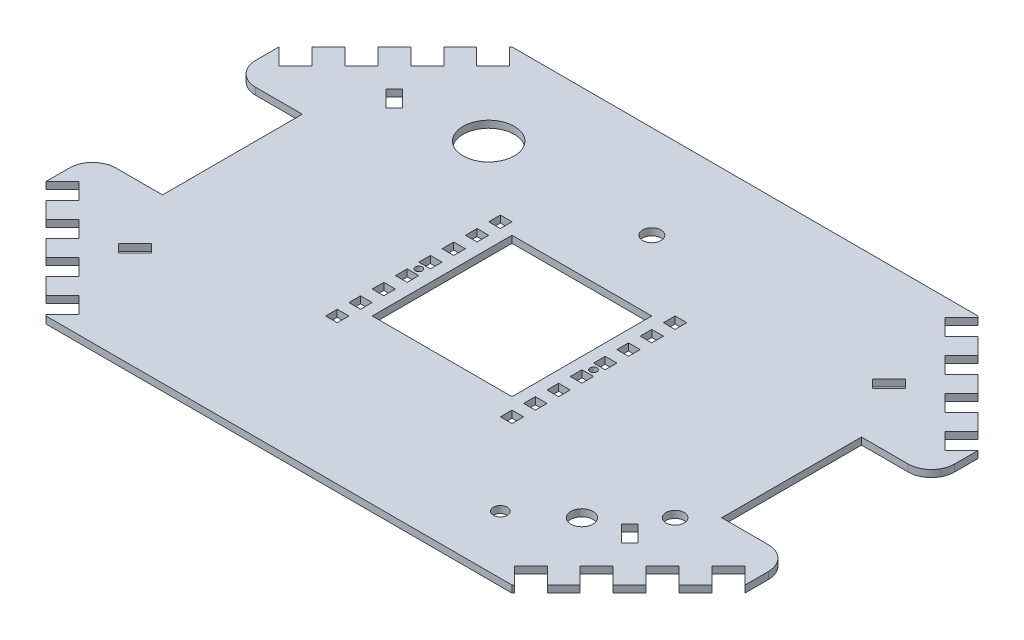
from build123d import *

# Parameters (mm, degrees)
ESQUISSE1_W                     = 300
ESQUISSE1_H                     = 200
BOSS_EXTRU_1_DEPTH              = 3
ENL_V_MAT_EXTRU_1_DEPTH         = 10
ESQUISSE3_W                     = 5
ESQUISSE3_H                     = 5
ENL_V_MAT_EXTRU_2_DEPTH         = 10
R_P_TITION_LIN_AIRE1_COUNT      = 2
R_P_TITION_LIN_AIRE1_PITCH      = 75
R_P_TITION_LIN_AIRE1_COUNT_DIR2 = 8
R_P_TITION_LIN_AIRE1_PITCH_DIR2 = 10
ENL_V_MAT_EXTRU_5_DEPTH         = 10
R_P_TITION_LIN_AIRE2_COUNT      = 4
R_P_TITION_LIN_AIRE2_PITCH      = 20
SYM_TRIE1_COPY_1_DEPTH          = 10
SYM_TRIE1_COPY_2_DEPTH          = 10
SYM_TRIE1_COPY_3_DEPTH          = 10
ESQUISSE9_R                     = 1.5
ENL_V_MAT_EXTRU_8_DEPTH         = 10
SYM_TRIE2_COPY_1_DEPTH          = 10
SYM_TRIE2_COPY_2_DEPTH          = 10
SYM_TRIE2_COPY_3_DEPTH          = 10
SYM_TRIE2_COPY_4_DEPTH          = 10
SYM_TRIE2_COPY_5_DEPTH          = 10
SYM_TRIE2_COPY_6_DEPTH          = 10
SYM_TRIE2_COPY_7_DEPTH          = 10
ESQUISSE11_R                    = 11
ESQUISSE11_R_2                  = 3.9
ESQUISSE11_R_3                  = 4.75
ESQUISSE11_R_4                  = 3
ESQUISSE11_R_5                  = 3.95
ENL_V_MAT_EXTRU_10_DEPTH        = 10
ESQUISSE12_W                    = 60
ESQUISSE12_H                    = 60
ENL_V_MAT_EXTRU_11_DEPTH        = 10
ESQUISSE13_W                    = 30
ESQUISSE13_H                    = 60
ENL_V_MAT_EXTRU_12_DEPTH        = 10
ENL_V_MAT_EXTRU_14_DEPTH        = 10
CONG_1_R                        = 10


with BuildPart() as part:
    # Esquisse1 → Boss.-Extru.1 (new body)
    with BuildSketch(Plane(origin=(0, 0, 0), x_dir=(1, 0, 0), z_dir=(0, 1, 0))):
        Rectangle(ESQUISSE1_W, ESQUISSE1_H)
    extrude(amount=BOSS_EXTRU_1_DEPTH)

    # Esquisse2 → Enlèv. mat.-Extru.1 (cut)
    with BuildSketch(Plane(origin=(0, 3, 0), x_dir=(1, 0, 0), z_dir=(0, 1, 0))):
        Polygon((-100, 100), (-150, 50), (-150, 100), align=None)
        Polygon((150, 100), (150, 50), (100, 100), align=None)
        Polygon((150, -100), (150, -50), (100, -100), align=None)
        Polygon((-100, -100), (-150, -100), (-150, -50), align=None)
    extrude(amount=-ENL_V_MAT_EXTRU_1_DEPTH, mode=Mode.SUBTRACT)

    # Esquisse3 → Enlèv. mat.-Extru.2 (cut)
    with BuildSketch(Plane(origin=(0, 3, 0), x_dir=(1, 0, 0), z_dir=(0, 1, 0))):
        with Locations((37.5, -37.5)):
            Rectangle(ESQUISSE3_W, ESQUISSE3_H)
    enl_v_mat_extru_2 = extrude(amount=-ENL_V_MAT_EXTRU_2_DEPTH, mode=Mode.SUBTRACT)

    # Répétition linéaire1: Enl_v. mat.-Extru.2 2 × 8
    with Locations(*[(-i * R_P_TITION_LIN_AIRE1_PITCH, 0, -j * R_P_TITION_LIN_AIRE1_PITCH_DIR2) for i in range(R_P_TITION_LIN_AIRE1_COUNT) for j in range(R_P_TITION_LIN_AIRE1_COUNT_DIR2) if (i, j) != (0, 0)]):
        add(enl_v_mat_extru_2, mode=Mode.SUBTRACT)

    # Esquisse6 → Enlèv. mat.-Extru.5 (cut)
    with BuildSketch(Plane(origin=(0, 3, 0), x_dir=(1, 0, 0), z_dir=(0, 1, 0))):
        Polygon((-142.928932188, 57.071067812), (-150, 50), (-142.928932188, 42.928932188), (-135.857864376, 50), align=None)
    enl_v_mat_extru_5 = extrude(amount=-ENL_V_MAT_EXTRU_5_DEPTH, mode=Mode.SUBTRACT)

    # Répétition linéaire2: Enlèv. mat.-Extru.5 ×4
    with Locations(*[Vector(0.707106781, 0, -0.707106781) * (i * R_P_TITION_LIN_AIRE2_PITCH) for i in range(1, R_P_TITION_LIN_AIRE2_COUNT)]):
        add(enl_v_mat_extru_5, mode=Mode.SUBTRACT)

    # Symétrie1: Enlèv. mat.-Extru.5 across plane
    add(enl_v_mat_extru_5.mirror(Plane.XY), mode=Mode.SUBTRACT)

    # Symétrie1 copy 1 sketch → Symétrie1 copy 1 (cut)
    with BuildSketch(Plane(origin=(14.142135624, 3, 14.142135624), x_dir=(1, 0, 0), z_dir=(0, 1, 0))):
        Polygon((-142.928932188, -57.071067812), (-150, -50), (-142.928932188, -42.928932188), (-135.857864376, -50), align=None)
    extrude(amount=-SYM_TRIE1_COPY_1_DEPTH, mode=Mode.SUBTRACT)

    # Symétrie1 copy 2 sketch → Symétrie1 copy 2 (cut)
    with BuildSketch(Plane(origin=(28.284271247, 3, 28.284271247), x_dir=(1, 0, 0), z_dir=(0, 1, 0))):
        Polygon((-142.928932188, -57.071067812), (-150, -50), (-142.928932188, -42.928932188), (-135.857864376, -50), align=None)
    extrude(amount=-SYM_TRIE1_COPY_2_DEPTH, mode=Mode.SUBTRACT)

    # Symétrie1 copy 3 sketch → Symétrie1 copy 3 (cut)
    with BuildSketch(Plane(origin=(42.426406871, 3, 42.426406871), x_dir=(1, 0, 0), z_dir=(0, 1, 0))):
        Polygon((-142.928932188, -57.071067812), (-150, -50), (-142.928932188, -42.928932188), (-135.857864376, -50), align=None)
    extrude(amount=-SYM_TRIE1_COPY_3_DEPTH, mode=Mode.SUBTRACT)

    # Esquisse9 → Enlèv. mat.-Extru.8 (cut)
    with BuildSketch(Plane(origin=(0, 3, 0), x_dir=(1, 0, 0), z_dir=(0, 1, 0))):
        with Locations((37.5, -2.5)):
            Circle(ESQUISSE9_R)
    enl_v_mat_extru_8 = extrude(amount=-ENL_V_MAT_EXTRU_8_DEPTH, mode=Mode.SUBTRACT)

    # Symétrie2: Enlèv. mat.-Extru.8, Enlèv. mat.-Extru.5 across plane
    add(enl_v_mat_extru_8.mirror(Plane(origin=(0, 0, 0), x_dir=(0, 0, 1), z_dir=(1, 0, 0))), mode=Mode.SUBTRACT)
    add(enl_v_mat_extru_5.mirror(Plane(origin=(0, 0, 0), x_dir=(0, 0, 1), z_dir=(1, 0, 0))), mode=Mode.SUBTRACT)

    # Symétrie2 copy 1 sketch → Symétrie2 copy 1 (cut)
    with BuildSketch(Plane(origin=(0, 3, 0), x_dir=(-1, 0, 0), z_dir=(0, 1, 0))):
        Polygon((-142.928932188, 57.071067812), (-150, 50), (-142.928932188, 42.928932188), (-135.857864376, 50), align=None)
    extrude(amount=-SYM_TRIE2_COPY_1_DEPTH, mode=Mode.SUBTRACT)

    # Symétrie2 copy 2 sketch → Symétrie2 copy 2 (cut)
    with BuildSketch(Plane(origin=(-14.142135624, 3, 14.142135624), x_dir=(-1, 0, 0), z_dir=(0, 1, 0))):
        Polygon((-142.928932188, 57.071067812), (-150, 50), (-142.928932188, 42.928932188), (-135.857864376, 50), align=None)
    extrude(amount=-SYM_TRIE2_COPY_2_DEPTH, mode=Mode.SUBTRACT)

    # Symétrie2 copy 3 sketch → Symétrie2 copy 3 (cut)
    with BuildSketch(Plane(origin=(-28.284271247, 3, 28.284271247), x_dir=(-1, 0, 0), z_dir=(0, 1, 0))):
        Polygon((-142.928932188, 57.071067812), (-150, 50), (-142.928932188, 42.928932188), (-135.857864376, 50), align=None)
    extrude(amount=-SYM_TRIE2_COPY_3_DEPTH, mode=Mode.SUBTRACT)

    # Symétrie2 copy 4 sketch → Symétrie2 copy 4 (cut)
    with BuildSketch(Plane(origin=(-42.426406871, 3, 42.426406871), x_dir=(-1, 0, 0), z_dir=(0, 1, 0))):
        Polygon((-142.928932188, 57.071067812), (-150, 50), (-142.928932188, 42.928932188), (-135.857864376, 50), align=None)
    extrude(amount=-SYM_TRIE2_COPY_4_DEPTH, mode=Mode.SUBTRACT)

    # Symétrie2 copy 5 sketch → Symétrie2 copy 5 (cut)
    with BuildSketch(Plane(origin=(-14.142135624, 3, -14.142135624), x_dir=(-1, 0, 0), z_dir=(0, 1, 0))):
        Polygon((-142.928932188, -57.071067812), (-150, -50), (-142.928932188, -42.928932188), (-135.857864376, -50), align=None)
    extrude(amount=-SYM_TRIE2_COPY_5_DEPTH, mode=Mode.SUBTRACT)

    # Symétrie2 copy 6 sketch → Symétrie2 copy 6 (cut)
    with BuildSketch(Plane(origin=(-28.284271247, 3, -28.284271247), x_dir=(-1, 0, 0), z_dir=(0, 1, 0))):
        Polygon((-142.928932188, -57.071067812), (-150, -50), (-142.928932188, -42.928932188), (-135.857864376, -50), align=None)
    extrude(amount=-SYM_TRIE2_COPY_6_DEPTH, mode=Mode.SUBTRACT)

    # Symétrie2 copy 7 sketch → Symétrie2 copy 7 (cut)
    with BuildSketch(Plane(origin=(-42.426406871, 3, -42.426406871), x_dir=(-1, 0, 0), z_dir=(0, 1, 0))):
        Polygon((-142.928932188, -57.071067812), (-150, -50), (-142.928932188, -42.928932188), (-135.857864376, -50), align=None)
    extrude(amount=-SYM_TRIE2_COPY_7_DEPTH, mode=Mode.SUBTRACT)

    # Esquisse11 → Enlèv. mat.-Extru.10 (cut)
    with BuildSketch(Plane(origin=(0, 3, 0), x_dir=(1, 0, 0), z_dir=(0, 1, 0))):
        with Locations((-70, 60)):
            Circle(ESQUISSE11_R)
        with Locations((110, -40)):
            Circle(ESQUISSE11_R_2)
        with Locations((90, -60)):
            Circle(ESQUISSE11_R_3)
        with Locations((70.071466061, -75.094818152)):
            Circle(ESQUISSE11_R_4)
        with Locations((0, 60)):
            Circle(ESQUISSE11_R_5)
    extrude(amount=-ENL_V_MAT_EXTRU_10_DEPTH, mode=Mode.SUBTRACT)

    # Esquisse12 → Enlèv. mat.-Extru.11 (cut)
    with BuildSketch(Plane(origin=(0, 3, 0), x_dir=(1, 0, 0), z_dir=(0, 1, 0))):
        Rectangle(ESQUISSE12_W, ESQUISSE12_H)
    extrude(amount=-ENL_V_MAT_EXTRU_11_DEPTH, mode=Mode.SUBTRACT)

    # Esquisse13 → Enlèv. mat.-Extru.12 (cut)
    with BuildSketch(Plane(origin=(0, 3, 0), x_dir=(1, 0, 0), z_dir=(0, 1, 0))):
        with Locations((-135, -0.001067812)):
            Rectangle(ESQUISSE13_W, ESQUISSE13_H)
        with Locations((135, -0.001067812)):
            Rectangle(ESQUISSE13_W, ESQUISSE13_H)
    extrude(amount=-ENL_V_MAT_EXTRU_12_DEPTH, mode=Mode.SUBTRACT)

    # Esquisse15 → Enlèv. mat.-Extru.14 (cut)
    with BuildSketch(Plane(origin=(0, 3, 0), x_dir=(1, 0, 0), z_dir=(0, 1, 0))):
        Polygon((-111.462680425, -57.424621202), (-104.391612613, -50.353553391), (-100.856078708, -53.889087297), (-107.927146519, -60.960155108), align=None)
        Polygon((107.927146519, -60.960155108), (100.856078708, -53.889087297), (104.391612613, -50.353553391), (111.462680425, -57.424621202), align=None)
        Polygon((111.462680425, 57.424621202), (104.391612613, 50.353553391), (100.856078708, 53.889087297), (107.927146519, 60.960155108), align=None)
        Polygon((-107.927146519, 60.960155108), (-100.856078708, 53.889087297), (-104.391612613, 50.353553391), (-111.462680425, 57.424621202), align=None)
    extrude(amount=-ENL_V_MAT_EXTRU_14_DEPTH, mode=Mode.SUBTRACT)

    # Congé1
    cong_1_edges = [part.edges().sort_by_distance(p)[0] for p in [
        (-150, 1.5, 30.001067812),
        (-150, 1.5, -29.998932188),
        (150, 1.5, 30.001067812),
        (150, 1.5, -29.998932188),
    ]]
    fillet(cong_1_edges, radius=CONG_1_R)


solid = part.part
